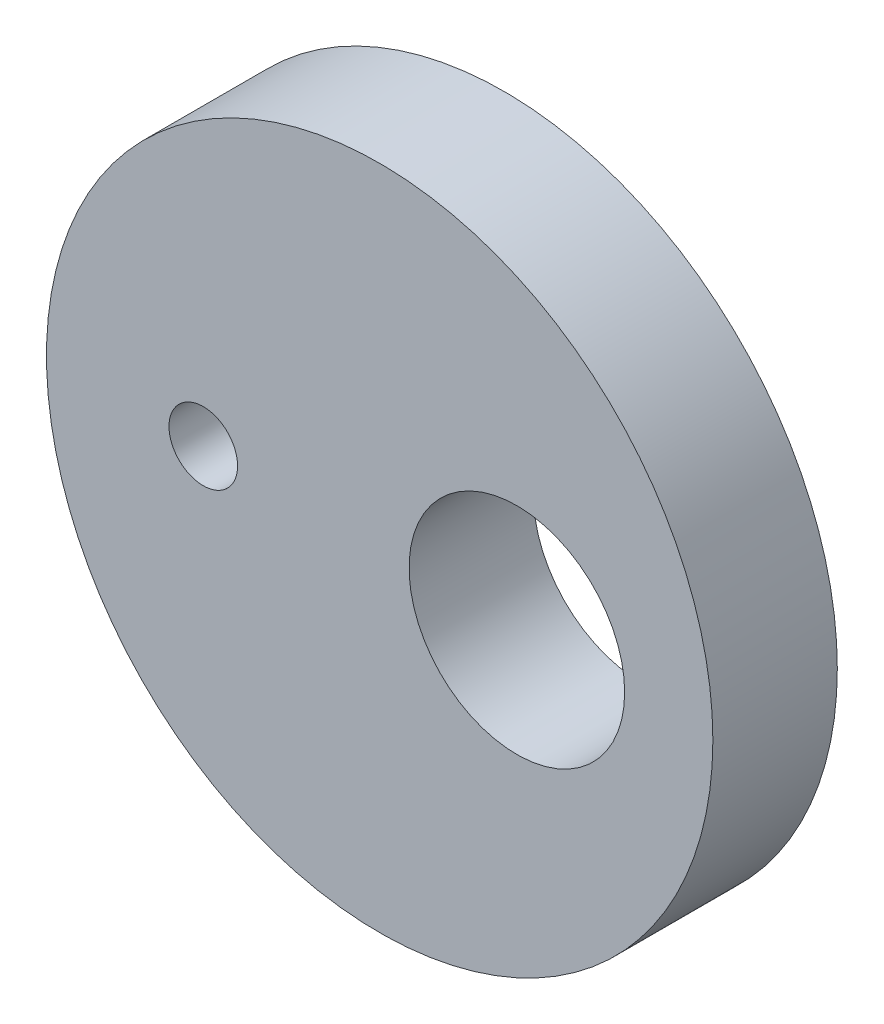
from build123d import *

# Parameters (mm, degrees)
SKETCH1_R           = 17
SKETCH1_R_2         = 1.75
SKETCH1_R_3         = 5.5
BOSS_EXTRUDE1_DEPTH = 6.35


with BuildPart() as part:
    # Sketch1 → Boss-Extrude1 (new body)
    with BuildSketch(Plane.XY):
        Circle(SKETCH1_R)
        with Locations((-9, 0)):
            Circle(SKETCH1_R_2, mode=Mode.SUBTRACT)
        with Locations((7, -0.12548824)):
            Circle(SKETCH1_R_3, mode=Mode.SUBTRACT)
    extrude(amount=BOSS_EXTRUDE1_DEPTH)


solid = part.part
